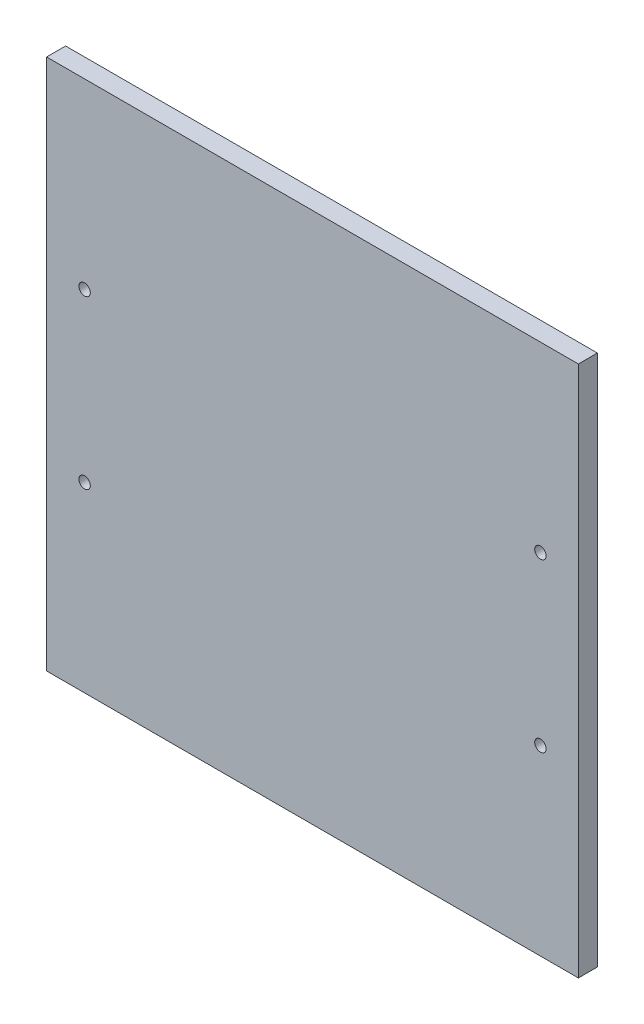
from build123d import *

# Parameters (mm, degrees)
SKETCH1_W                                       = 140
SKETCH1_H                                       = 140
BOSS_EXTRUDE1_DEPTH                             = 5
CSK_FOR_M3_FLAT_HEAD_MACHINE_SCREW1_D           = 3
CSK_FOR_M3_FLAT_HEAD_MACHINE_SCREW1_CSINK_D     = 8
CSK_FOR_M3_FLAT_HEAD_MACHINE_SCREW1_CSINK_ANGLE = 90


with BuildPart() as part:
    # Sketch1 → Boss-Extrude1 (new body)
    with BuildSketch(Plane.XY):
        with Locations((70, 70)):
            Rectangle(SKETCH1_W, SKETCH1_H)
    extrude(amount=BOSS_EXTRUDE1_DEPTH)

    # CSK for M3 Flat Head Machine Screw1 (through all)
    with Locations(Plane(origin=(0, 0, 0), x_dir=(-1, 0, 0), z_dir=(0, 0, -1))):
        with Locations((-130, 92), (-130, 48), (-10, 92), (-10, 48)):
            CounterSinkHole(CSK_FOR_M3_FLAT_HEAD_MACHINE_SCREW1_D / 2, CSK_FOR_M3_FLAT_HEAD_MACHINE_SCREW1_CSINK_D / 2, counter_sink_angle=CSK_FOR_M3_FLAT_HEAD_MACHINE_SCREW1_CSINK_ANGLE)


solid = part.part
